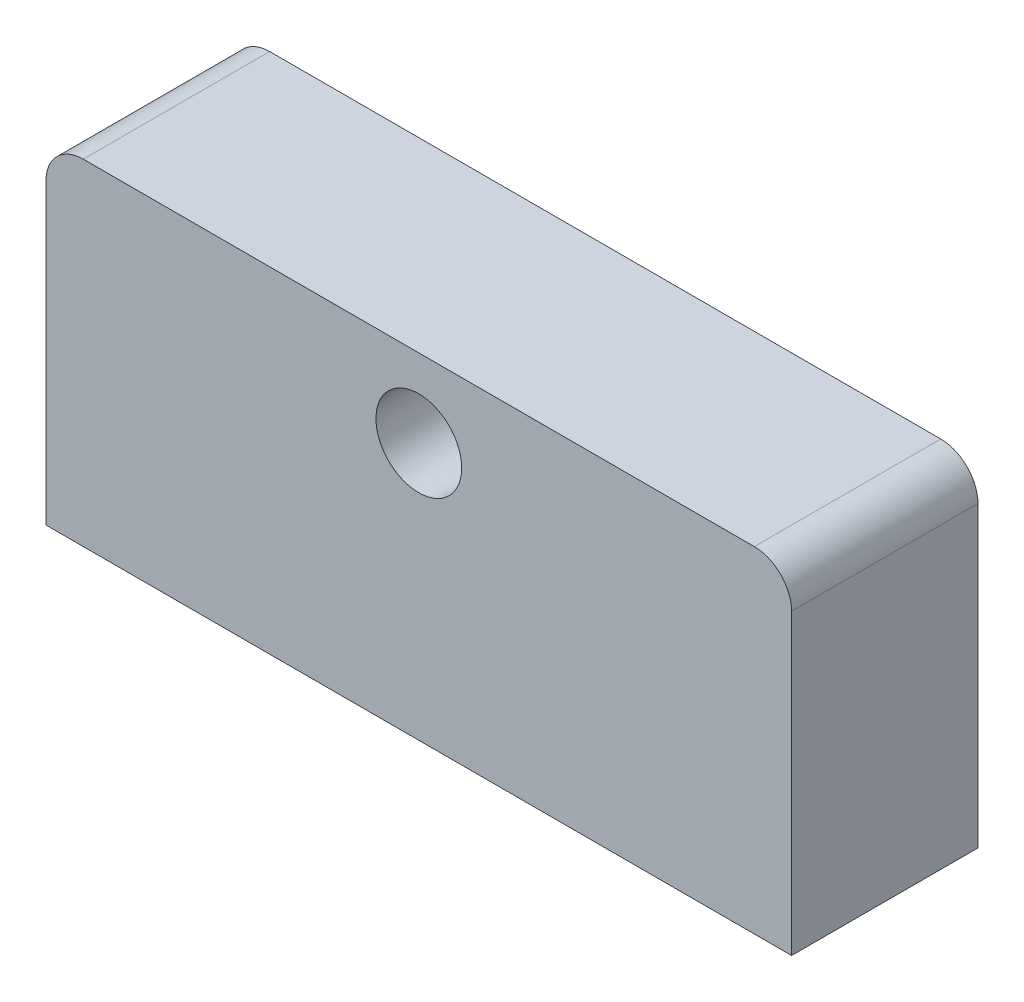
from build123d import *

# Parameters (mm, degrees)
SKETCH1_W           = 200
SKETCH1_H           = 90
SKETCH1_R           = 11.5
BOSS_EXTRUDE1_DEPTH = 25
SKETCH2_R           = 1.75
CUT_EXTRUDE1_DEPTH  = 10
SKETCH3_R           = 5
CUT_EXTRUDE2_DEPTH  = 15
FILLET1_R           = 10


with BuildPart() as part:
    # Sketch1 → Boss-Extrude1 (new body, symmetric)
    with BuildSketch(Plane.XY):
        Rectangle(SKETCH1_W, SKETCH1_H)
        with Locations((0, 24)):
            Circle(SKETCH1_R, mode=Mode.SUBTRACT)
    extrude(amount=BOSS_EXTRUDE1_DEPTH, both=True)

    # Sketch2 → Cut-Extrude1 (cut)
    with BuildSketch(Plane(origin=(0, 0, -25), x_dir=(-1, 0, 0), z_dir=(0, 0, -1))):
        with Locations((-15.5, 8.5)):
            Circle(SKETCH2_R)
        with Locations((15.5, 8.5)):
            Circle(SKETCH2_R)
        with Locations((15.5, 39.5)):
            Circle(SKETCH2_R)
        with Locations((-15.5, 39.5)):
            Circle(SKETCH2_R)
    extrude(amount=-CUT_EXTRUDE1_DEPTH, mode=Mode.SUBTRACT)

    # Sketch3 → Cut-Extrude2 (cut)
    with BuildSketch(Plane.XZ.offset(45)):
        with Locations((-50, 0)):
            Circle(SKETCH3_R)
        with Locations((50, 0)):
            Circle(SKETCH3_R)
    extrude(amount=-CUT_EXTRUDE2_DEPTH, mode=Mode.SUBTRACT)

    # Fillet1
    fillet1_edges = [part.edges().sort_by_distance(p)[0] for p in [
        (100, 45, 0),
        (-100, 45, 0),
    ]]
    fillet(fillet1_edges, radius=FILLET1_R)


solid = part.part
